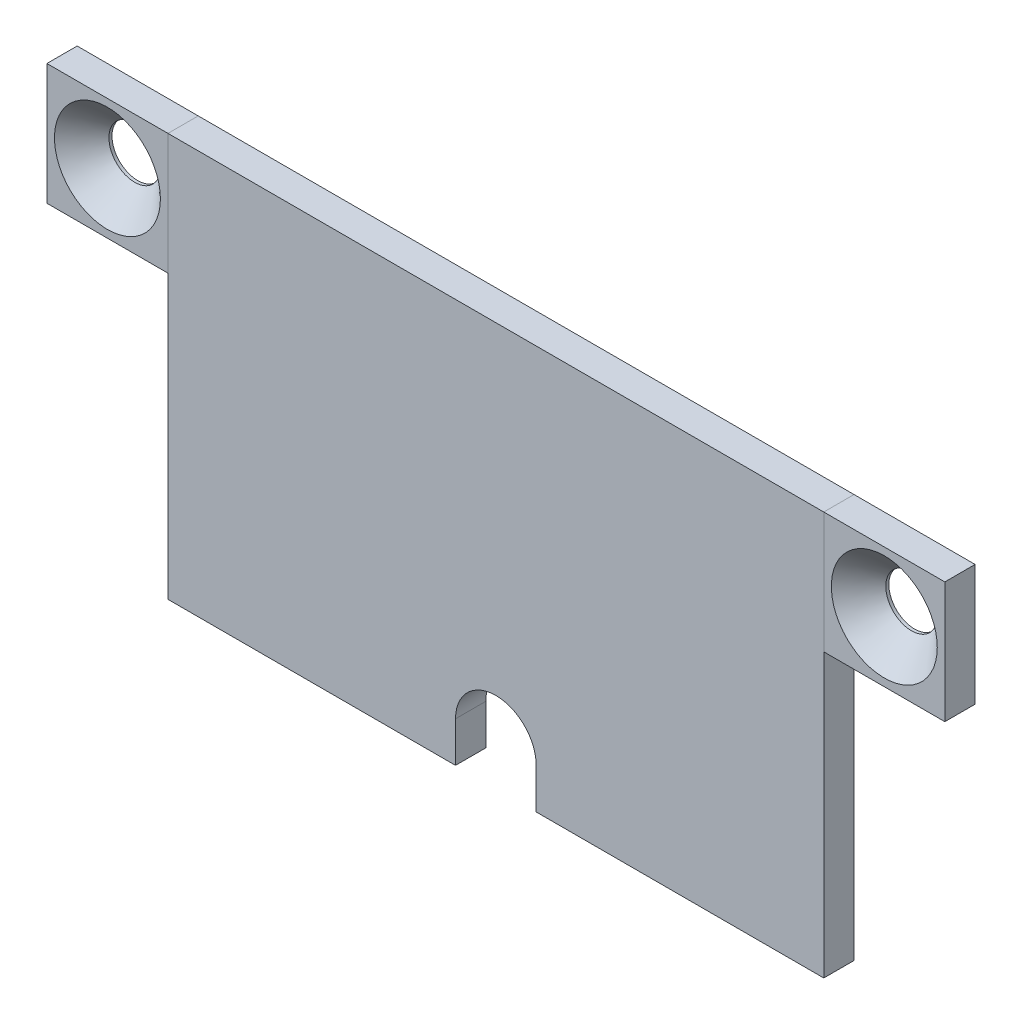
from build123d import *

# Parameters (mm, degrees)
ESQUISSE1_W                                = 65
ESQUISSE1_H                                = 40
BOSS_EXTRU_1_DEPTH                         = 3
ESQUISSE2_W                                = 12
ESQUISSE2_H                                = 12
BOSS_EXTRU_2_DEPTH                         = 3
BOSS_EXTRU_2_2_DEPTH                       = 3
ENL_V_MAT_EXTRU_1_DEPTH                    = 4
FRAISAGE_POUR_VIS_T_TE_FRAIS_E_BOM_2_COUNT = 2
FRAISAGE_POUR_VIS_T_TE_FRAIS_E_BOM_2_PITCH = 77


with BuildPart() as part:
    # Esquisse1 → Boss.-Extru.1 (new body)
    with BuildSketch(Plane.XY):
        with Locations((-2.405605858, 33.162869601)):
            Rectangle(ESQUISSE1_W, ESQUISSE1_H)
    extrude(amount=BOSS_EXTRU_1_DEPTH)

    # Esquisse4 → Enlèv. mat.-Extru.1 (cut, through all)
    with BuildSketch(Plane.XY.offset(3)):
        with BuildLine():
            Line((-6.405605858, 17.162869601), (-6.405605858, 13.162869601))
            Line((-6.405605858, 13.162869601), (1.594394142, 13.162869601))
            Line((1.594394142, 13.162869601), (1.594394142, 17.162868612))
            ThreePointArc((1.594394142, 17.162868612), (-2.405605364, 21.162869107), (-6.405605858, 17.162869601))
        make_face()
    extrude(amount=-ENL_V_MAT_EXTRU_1_DEPTH, mode=Mode.SUBTRACT)


with BuildPart() as body_2:
    # Esquisse2 → Boss.-Extru.2 (new body)
    with BuildSketch(Plane.XY.offset(3)):
        with Locations((-40.905605858, 47.162869601)):
            Rectangle(ESQUISSE2_W, ESQUISSE2_H)
    extrude(amount=-BOSS_EXTRU_2_DEPTH)

    # Esquisse6 → Fraisage pour vis à tête fraisée bombée #51 (revolve, cut)
    with BuildSketch(Plane(origin=(-40.905605858, 47.162869601, 3), x_dir=(0, -1, 0), z_dir=(1, 0, 0))):
        Polygon((0, 0), (0, 3), (2.54999998, 3), (2.54999998, 2.700000061), (5.250000041, 0), align=None)
    fraisage_pour_vis_t_te_frais_e_bomb_e = revolve(axis=Axis((-40.905605858, 47.162869601, 9.35), (0, 0, -1)), mode=Mode.SUBTRACT)


with BuildPart() as body_3:
    # Esquisse2 → Boss.-Extru.2 2 (new body)
    with BuildSketch(Plane.XY.offset(3)):
        with Locations((36.094394142, 47.162869601)):
            Rectangle(ESQUISSE2_W, ESQUISSE2_H)
    extrude(amount=-BOSS_EXTRU_2_2_DEPTH)

    # Fraisage pour vis _ t_te frais_e bom 2: Fraisage pour vis à tête fraisée bombée #51 ×2
    with Locations(*[(i * FRAISAGE_POUR_VIS_T_TE_FRAIS_E_BOM_2_PITCH, 0, 0) for i in range(1, FRAISAGE_POUR_VIS_T_TE_FRAIS_E_BOM_2_COUNT)]):
        add(fraisage_pour_vis_t_te_frais_e_bomb_e, mode=Mode.SUBTRACT)


solid = Compound([part.part, body_2.part, body_3.part])
